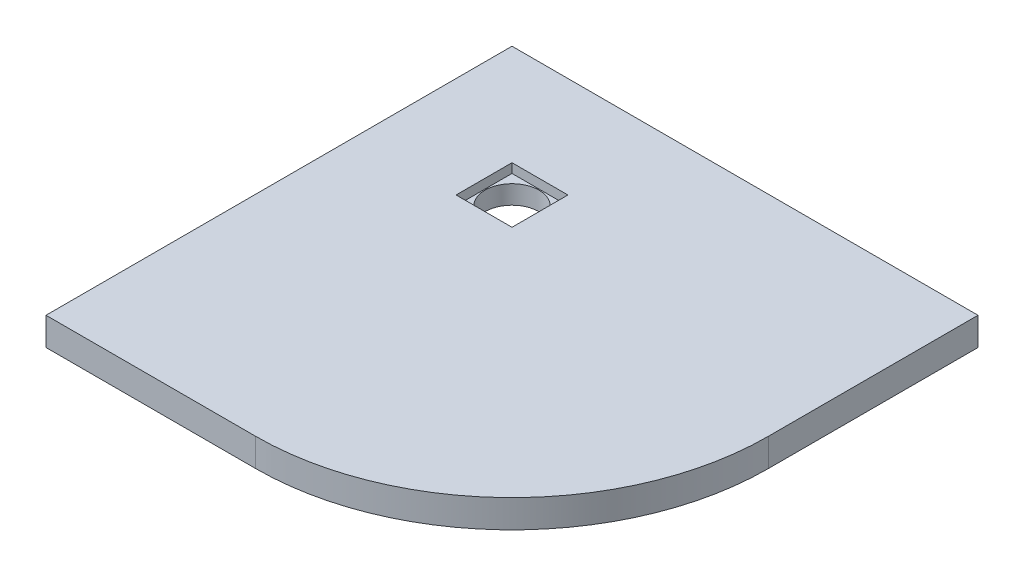
from build123d import *

# Parameters (mm, degrees)
SKIZZE1_W                       = 1000
SKIZZE1_H                       = 60
AUFSATZ_LINEAR_AUSTRAGEN1_DEPTH = 1000
SCHNITT_LINEAR_AUSTRAGEN1_DEPTH = 1000
SKIZZE3_R                       = 58
SCHNITT_LINEAR_AUSTRAGEN2_DEPTH = 61
SKIZZE4_W                       = 120
SKIZZE4_H                       = 120
SCHNITT_LINEAR_AUSTRAGEN3_DEPTH = 20


with BuildPart() as part:
    # Skizze1 → Aufsatz-Linear austragen1 (new body)
    with BuildSketch(Plane.XY):
        with Locations((500, 30)):
            Rectangle(SKIZZE1_W, SKIZZE1_H)
    extrude(amount=AUFSATZ_LINEAR_AUSTRAGEN1_DEPTH)

    # Skizze2 → Schnitt-Linear austragen1 (cut)
    with BuildSketch(Plane(origin=(0, 60, 0), x_dir=(1, 0, 0), z_dir=(0, 1, 0))):
        with BuildLine():
            Line((1000, -1000), (1000, -450))
            ThreePointArc((1000, -450), (838.908729653, -838.908729653), (450, -1000))
            Line((450, -1000), (1000, -1000))
        make_face()
    extrude(amount=-SCHNITT_LINEAR_AUSTRAGEN1_DEPTH, mode=Mode.SUBTRACT)

    # Skizze3 → Schnitt-Linear austragen2 (cut, through all)
    with BuildSketch(Plane(origin=(0, 60, 0), x_dir=(1, 0, 0), z_dir=(0, 1, 0))):
        with Locations(Location((276.5, -276.5, 0), (0, 0, 270))):  # turned: the seam where the file's is
            Circle(SKIZZE3_R)
    extrude(amount=-SCHNITT_LINEAR_AUSTRAGEN2_DEPTH, mode=Mode.SUBTRACT)

    # Skizze4 → Schnitt-Linear austragen3 (cut)
    with BuildSketch(Plane(origin=(0, 60, 0), x_dir=(1, 0, 0), z_dir=(0, 1, 0))):
        with Locations((276.5, -276.5)):
            Rectangle(SKIZZE4_W, SKIZZE4_H)
    extrude(amount=-SCHNITT_LINEAR_AUSTRAGEN3_DEPTH, mode=Mode.SUBTRACT)


solid = part.part
